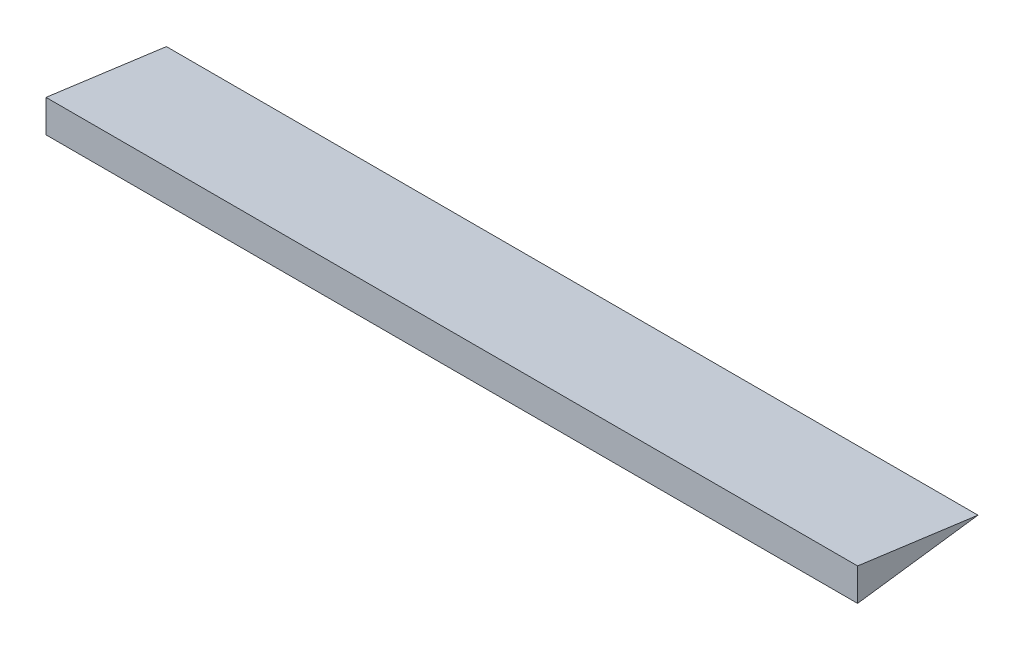
from build123d import *

# Parameters (mm, degrees)
BOSS_EXTRUDE1_DEPTH = 168.5


with BuildPart() as part:
    # aileron_root → Boss-Extrude1 (new, symmetric)
    with BuildSketch(Plane(origin=(0, 0, 0), x_dir=(0, 0, -1), z_dir=(1, 0, 0))):
        Polygon((-50, -6.738836743), (-50, 6.738836743), (0, 0), align=None)
    extrude(amount=BOSS_EXTRUDE1_DEPTH, both=True)


solid = part.part
